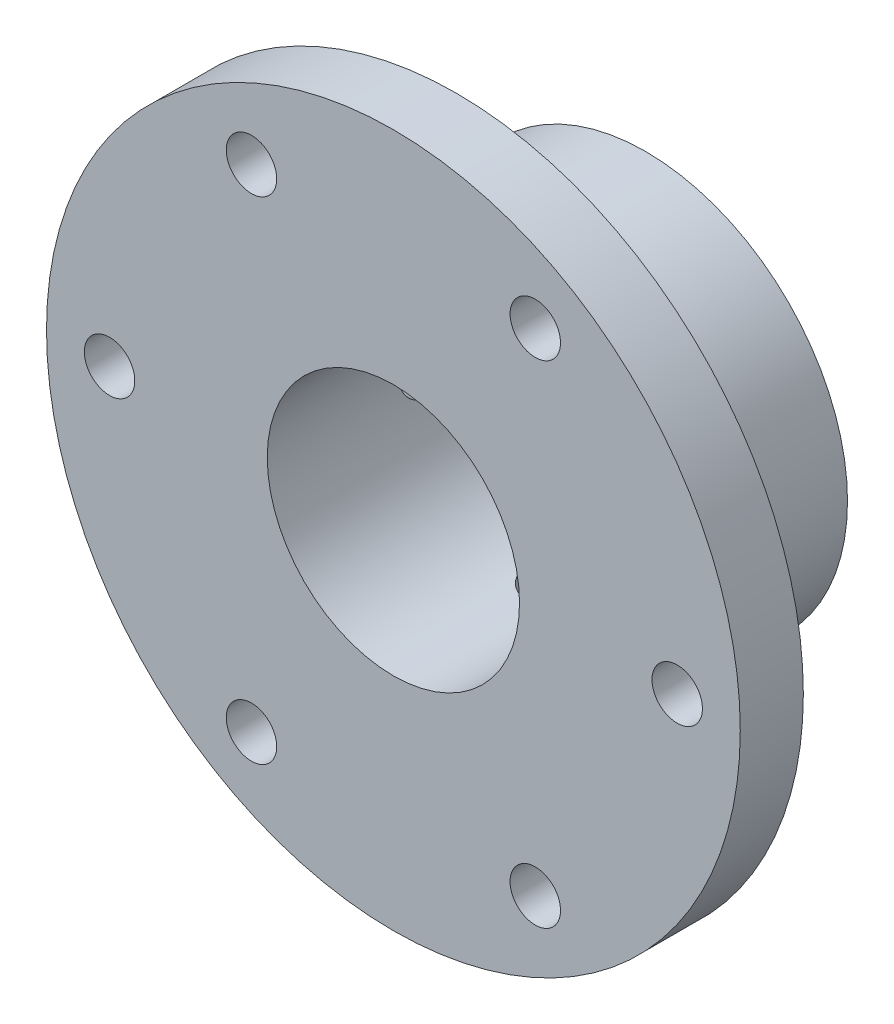
from build123d import *

# Parameters (mm, degrees)
SKETCH_1_R               = 27.5
EXTRUDE_1_DEPTH          = 5
SKETCH_2_R               = 10
CUT_EXTRUDE_2_DEPTH      = 40.210967853
EXTRUDE_START            = 15
SKETCH_2_12_R            = 16
SKETCH_2_12_R_2          = 10
EXTRUDE_9_DEPTH          = 15
SKETCH_12_R              = 2
CUT_EXTRUDE_3_DEPTH      = 42.683330001
CHAMFER_1_SIZE           = 0.5
CUT_EXTRUDE_4_REACH      = 55.605
SKETCH_13_R              = 2
PATTERN_CIRCULAR_1_COUNT = 4


with BuildPart() as part:
    # Эскиз1 → Бобышка-Вытянуть1 (new body)
    with BuildSketch(Plane.XY):
        Circle(SKETCH_1_R)
    extrude(amount=EXTRUDE_1_DEPTH)

    # Эскиз2 → Вырез-Вытянуть2 (cut, through all)
    with BuildSketch(Plane(origin=(0, 0, 0), x_dir=(-1, 0, 0), z_dir=(0, 0, -1))):
        Circle(SKETCH_2_R)
    extrude(amount=-CUT_EXTRUDE_2_DEPTH, mode=Mode.SUBTRACT)

    # Эскиз2<12> → Бобышка-Вытянуть9 (add)
    with BuildSketch(Plane(origin=(0, 0, 0), x_dir=(-1, 0, 0), z_dir=(0, 0, -1)).offset(EXTRUDE_START)):
        Circle(SKETCH_2_12_R)
        Circle(SKETCH_2_12_R_2, mode=Mode.SUBTRACT)
    extrude(amount=-EXTRUDE_9_DEPTH)

    # Эскиз12 → Вырез-Вытянуть3 (cut, through all)
    with BuildSketch(Plane(origin=(0, 0, 0), x_dir=(-1, 0, 0), z_dir=(0, 0, -1))):
        with Locations((-22.5, 0)):
            Circle(SKETCH_12_R)
        with Locations((-11.25, 19.485571585)):
            Circle(SKETCH_12_R)
        with Locations((11.25, 19.485571585)):
            Circle(SKETCH_12_R)
        with Locations((22.5, 0)):
            Circle(SKETCH_12_R)
        with Locations((11.25, -19.485571585)):
            Circle(SKETCH_12_R)
        with Locations((-11.25, -19.485571585)):
            Circle(SKETCH_12_R)
    extrude(amount=-CUT_EXTRUDE_3_DEPTH, mode=Mode.SUBTRACT)

    # Фаска1
    chamfer_1_edges = [part.edges().sort_by_distance(p)[0] for p in [
        (-20.5, 0, 0),
        (-9.25, -19.485571585, 0),
        (13.25, -19.485571585, 0),
        (24.5, 0, 0),
        (-9.25, 19.485571585, 0),
        (13.25, 19.485571585, 0),
    ]]
    chamfer(chamfer_1_edges, length=CHAMFER_1_SIZE)

    # Эскиз13 → Вырез-Вытянуть4 (cut, up to next)
    with BuildSketch(Plane(origin=(0, 16, 0), x_dir=(1, 0, 0), z_dir=(0, 1, 0)), mode=Mode.PRIVATE) as cut_extrude_4_sk1:
        with Locations((0, 7.5)):
            Circle(SKETCH_13_R)
    cut_extrude_4_tool1 = extrude(cut_extrude_4_sk1.sketch, amount=-CUT_EXTRUDE_4_REACH, mode=Mode.PRIVATE) & part.part
    cut_extrude_4 = cut_extrude_4_tool1.solids().sort_by_distance((0, 16, -7.5))[0]
    add(cut_extrude_4, mode=Mode.SUBTRACT)

    # Круговой массив1: Вырез-Вытянуть4 ×4 about axis
    pattern_circular_1_axis = Axis((0, 0, -15), (0, 0, 1))
    for i in range(1, PATTERN_CIRCULAR_1_COUNT):
        add(cut_extrude_4.rotate(pattern_circular_1_axis, i * 360 / PATTERN_CIRCULAR_1_COUNT), mode=Mode.SUBTRACT)


solid = part.part
